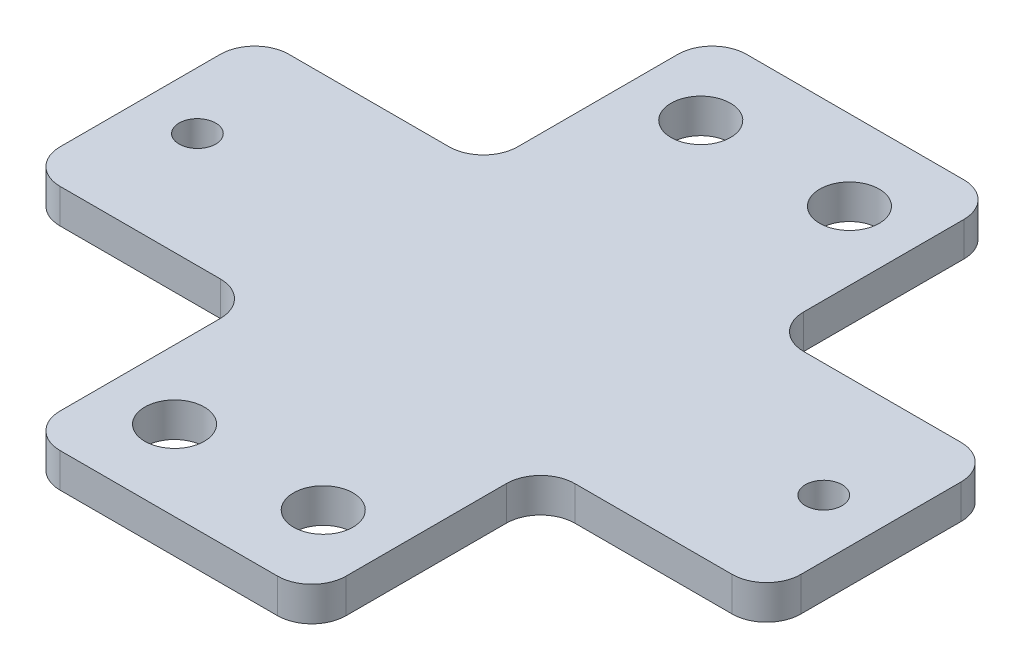
from build123d import *

# Parameters (mm, degrees)
SKETCH_1_W      = 25
SKETCH_1_H      = 60
SKETCH_1_R      = 2.6
EXTRUDE_1_DEPTH = 3
SKETCH_2_W      = 20
SKETCH_2_H      = 20
SKETCH_2_R      = 1.6
SKETCH_2_W_2    = 19.75
EXTRUDE_2_DEPTH = 3
FILLET_1_R      = 3


with BuildPart() as part:
    # 草图1 → 凸台-拉伸1 (new body)
    with BuildSketch(Plane(origin=(0, 0, 0), x_dir=(1, 0, 0), z_dir=(0, 1, 0))):
        with Locations((12.5, 30)):
            Rectangle(SKETCH_1_W, SKETCH_1_H)
        with Locations((6, 7)):
            Circle(SKETCH_1_R, mode=Mode.SUBTRACT)
        with Locations((19, 7)):
            Circle(SKETCH_1_R, mode=Mode.SUBTRACT)
        with Locations((6, 53)):
            Circle(SKETCH_1_R, mode=Mode.SUBTRACT)
        with Locations((19, 53)):
            Circle(SKETCH_1_R, mode=Mode.SUBTRACT)
    extrude(amount=EXTRUDE_1_DEPTH)

    # 草图2 → 凸台-拉伸2 (add)
    with BuildSketch(Plane(origin=(0, 3, 0), x_dir=(1, 0, 0), z_dir=(0, 1, 0))):
        with Locations((-10, 30)):
            Rectangle(SKETCH_2_W, SKETCH_2_H)
        with Locations((-15, 30)):
            Circle(SKETCH_2_R, mode=Mode.SUBTRACT)
        with Locations((34.875, 30)):
            Rectangle(SKETCH_2_W_2, SKETCH_2_H)
        with Locations((39.75, 30)):
            Circle(SKETCH_2_R, mode=Mode.SUBTRACT)
    extrude(amount=-EXTRUDE_2_DEPTH)

    # 圆角1
    fillet_1_edges = [part.edges().sort_by_distance(p)[0] for p in [
        (0, 1.5, -40),
        (0, 1.5, -20),
        (-20, 1.5, -20),
        (-20, 1.5, -40),
        (25, 1.5, -20),
        (25, 1.5, -40),
        (44.75, 1.5, -40),
        (44.75, 1.5, -20),
        (0, 1.5, -60),
        (25, 1.5, -60),
        (25, 1.5, 0),
        (0, 1.5, 0),
    ]]
    fillet(fillet_1_edges, radius=FILLET_1_R)


solid = part.part
